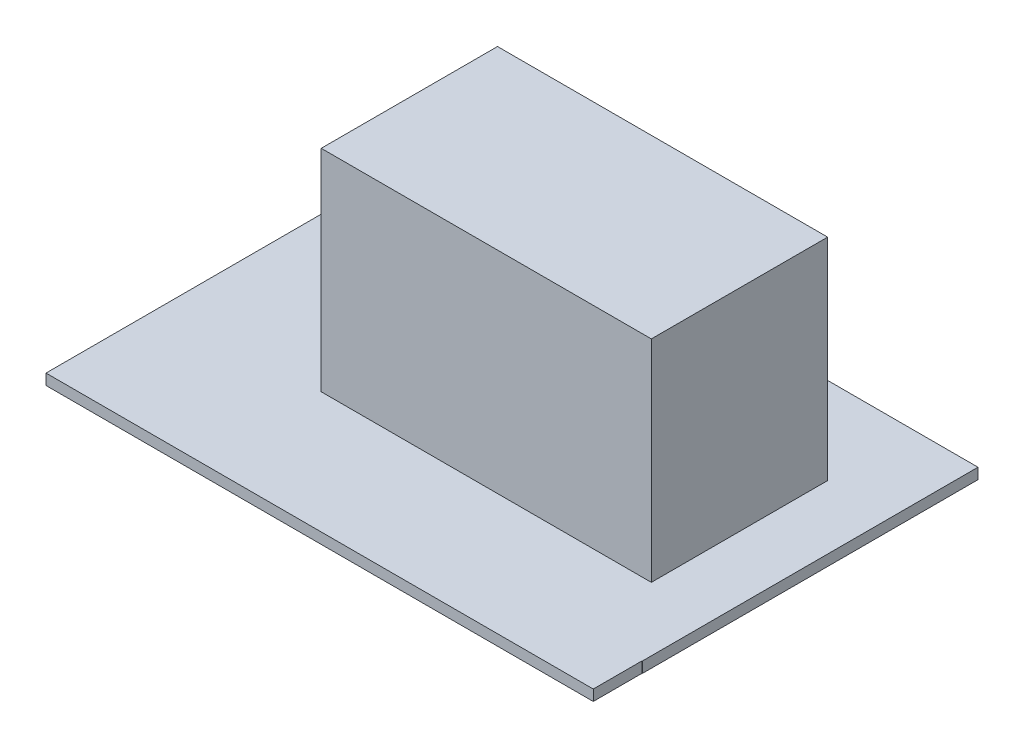
from build123d import *

# Parameters (mm, degrees)
BOSS_EXTRUDE1_DEPTH = 1.5875
SKETCH2_W           = 36.068
SKETCH2_H           = 1.5875
BOSS_EXTRUDE2_DEPTH = 21.2725
SKETCH3_W           = 1.5875
SKETCH3_H           = 25.654
BOSS_EXTRUDE3_DEPTH = 6.35
HOLE1_D             = 5.08
HOLE1_DEPTH         = 15.875
SKETCH9_W           = 48.514
SKETCH9_H           = 25.908
BOSS_EXTRUDE4_DEPTH = 30.988
SKETCH11_W          = 80.424320956
SKETCH11_H          = 56.498512817
BOSS_EXTRUDE5_DEPTH = 1.5875


with BuildPart() as part:
    # Sketch1 → Boss-Extrude1 (new body)
    with BuildSketch(Plane(origin=(0, 0, 0), x_dir=(1, 0, 0), z_dir=(0, 1, 0))):
        Polygon((0, 0), (0, -25.4), (13.2588, -56.388), (31.9532, -56.388), (31.9532, -49.3268), (80.4672, -49.3268), (80.4672, 0), align=None)
    extrude(amount=BOSS_EXTRUDE1_DEPTH)

    # Sketch2 → Boss-Extrude2 (add)
    with BuildSketch(Plane.XZ):
        with Locations((18.034, 0.79375)):
            Rectangle(SKETCH2_W, SKETCH2_H)
    extrude(amount=BOSS_EXTRUDE2_DEPTH)

    # Sketch3 → Boss-Extrude3 (add)
    with BuildSketch(Plane.XY.offset(1.5875)):
        with Locations((35.27425, -21.971)):
            Rectangle(SKETCH3_W, SKETCH3_H)
        with Locations((0.79375, -21.971)):
            Rectangle(SKETCH3_W, SKETCH3_H)
    extrude(amount=BOSS_EXTRUDE3_DEPTH)

    # Hole1
    with Locations(Plane(origin=(0, 0, 0), x_dir=(-1, 0, 0), z_dir=(0, 0, -1))):
        with Locations((-18.034, -9.8425)):
            Hole(HOLE1_D / 2, depth=HOLE1_DEPTH)

    # Sketch9 → Boss-Extrude4 (add)
    with BuildSketch(Plane(origin=(0, 1.5875, 0), x_dir=(1, 0, 0), z_dir=(0, 1, 0))):
        with Locations((46.863, -25.7048)):
            Rectangle(SKETCH9_W, SKETCH9_H)
    extrude(amount=BOSS_EXTRUDE4_DEPTH)

    # Sketch11 → Boss-Extrude5 (add)
    with BuildSketch(Plane(origin=(0, 1.5875, 0), x_dir=(1, 0, 0), z_dir=(0, 1, 0))):
        with Locations((40.212160478, -28.249256409)):
            Rectangle(SKETCH11_W, SKETCH11_H)
    extrude(amount=-BOSS_EXTRUDE5_DEPTH)


solid = part.part
